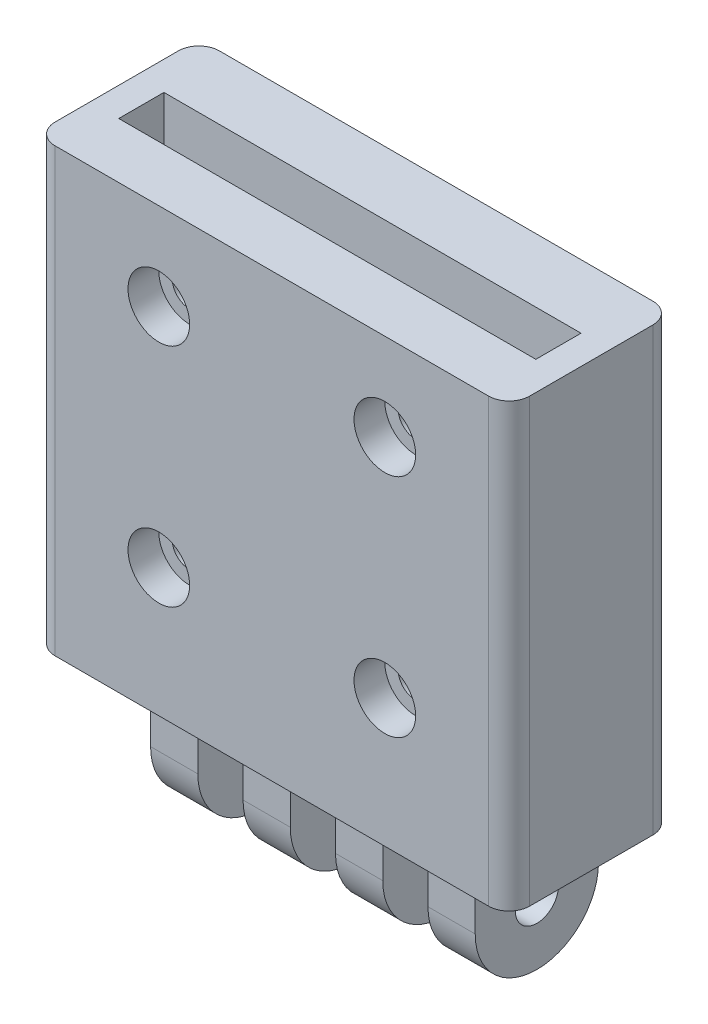
from build123d import *

# Parameters (mm, degrees)
SKETCH1_W            = 46.2
SKETCH1_H            = 16
BOSS_EXTRUDE1_DEPTH  = 43
SKETCH2_W            = 4.6
SKETCH2_H            = 12
BOSS_EXTRUDE2_DEPTH  = 7
SKETCH8_R            = 6
BOSS_EXTRUDE3_DEPTH  = 4.6
LPATTERN1_COUNT      = 4
LPATTERN1_PITCH      = 9
SKETCH4_R            = 2.1
CUT_EXTRUDE1_DEPTH   = 39.9
SKETCH6_W            = 40.6
SKETCH6_H            = 4.4
CUT_EXTRUDE2_DEPTH   = 40
SKETCH9_R            = 1.7
CUT_EXTRUDE3_DEPTH   = 17
FILLET2_R            = 2
CUT_EXTRUDE4_DEPTH   = 4
LPATTERN2_COUNT      = 2
LPATTERN2_PITCH      = 22
LPATTERN2_COUNT_DIR2 = 2
LPATTERN2_PITCH_DIR2 = 22
SKETCH11_R           = 3
CUT_EXTRUDE5_DEPTH   = 3


with BuildPart() as part:
    # Sketch1 → Boss-Extrude1 (new body)
    with BuildSketch(Plane(origin=(0, 0, 0), x_dir=(1, 0, 0), z_dir=(0, 1, 0))):
        Rectangle(SKETCH1_W, SKETCH1_H)
    extrude(amount=BOSS_EXTRUDE1_DEPTH)

    # Sketch2 → Boss-Extrude2 (add)
    with BuildSketch(Plane.XZ):
        with Locations((13.5, -2)):
            Rectangle(SKETCH2_W, SKETCH2_H)
    boss_extrude2 = extrude(amount=BOSS_EXTRUDE2_DEPTH)

    # Sketch8 → Boss-Extrude3 (add)
    with BuildSketch(Plane(origin=(15.8, 0, 0), x_dir=(0, 0, -1), z_dir=(1, 0, 0))):
        with Locations((2, -7)):
            Circle(SKETCH8_R)
    boss_extrude3 = extrude(amount=-BOSS_EXTRUDE3_DEPTH)

    # LPattern1: Boss-Extrude2, Boss-Extrude3 ×4
    with Locations(*[(-i * LPATTERN1_PITCH, 0, 0) for i in range(1, LPATTERN1_COUNT)]):
        add(boss_extrude2)
        add(boss_extrude3)

    # Sketch4 → Cut-Extrude1 (cut, through all)
    with BuildSketch(Plane(origin=(15.8, 0, 0), x_dir=(0, 0, -1), z_dir=(1, 0, 0))):
        with Locations((2, -7)):
            Circle(SKETCH4_R)
    extrude(amount=-CUT_EXTRUDE1_DEPTH, mode=Mode.SUBTRACT)

    # Sketch6 → Cut-Extrude2 (cut)
    with BuildSketch(Plane(origin=(0, 43, 0), x_dir=(1, 0, 0), z_dir=(0, 1, 0))):
        with Locations((0, -0.4)):
            Rectangle(SKETCH6_W, SKETCH6_H)
    extrude(amount=-CUT_EXTRUDE2_DEPTH, mode=Mode.SUBTRACT)

    # Sketch9 → Cut-Extrude3 (cut, through all)
    with BuildSketch(Plane.XY.offset(8)):
        with Locations((11, 12.5)):
            Circle(SKETCH9_R)
        with Locations((-11, 12.5)):
            Circle(SKETCH9_R)
        with Locations((11, 34.5)):
            Circle(SKETCH9_R)
        with Locations((-11, 34.5)):
            Circle(SKETCH9_R)
    extrude(amount=-CUT_EXTRUDE3_DEPTH, mode=Mode.SUBTRACT)

    # Fillet2
    fillet2_edges = [part.edges().sort_by_distance(p)[0] for p in [
        (-23.1, 21.5, -8),
        (23.1, 21.5, -8),
        (23.1, 21.5, 8),
        (-23.1, 21.5, 8),
    ]]
    fillet(fillet2_edges, radius=FILLET2_R)

    # Sketch10 → Cut-Extrude4 (cut)
    with BuildSketch(Plane(origin=(0, 0, -8), x_dir=(-1, 0, 0), z_dir=(0, 0, -1))):
        Polygon((12.58771324, 9.75), (9.41228676, 9.75), (7.824573519, 12.5), (9.41228676, 15.25), (12.58771324, 15.25), (14.175426481, 12.5), align=None)
    cut_extrude4 = extrude(amount=-CUT_EXTRUDE4_DEPTH, mode=Mode.SUBTRACT)

    # LPattern2: Cut-Extrude4 2 × 2
    with Locations(*[(j * LPATTERN2_PITCH_DIR2, i * LPATTERN2_PITCH, 0) for i in range(LPATTERN2_COUNT) for j in range(LPATTERN2_COUNT_DIR2) if (i, j) != (0, 0)]):
        add(cut_extrude4, mode=Mode.SUBTRACT)

    # Sketch11 → Cut-Extrude5 (cut)
    with BuildSketch(Plane.XY.offset(8)):
        with Locations((11, 12.5)):
            Circle(SKETCH11_R)
        with Locations((-11, 12.5)):
            Circle(SKETCH11_R)
        with Locations((-11, 34.5)):
            Circle(SKETCH11_R)
        with Locations((11, 34.5)):
            Circle(SKETCH11_R)
    extrude(amount=-CUT_EXTRUDE5_DEPTH, mode=Mode.SUBTRACT)


solid = part.part
